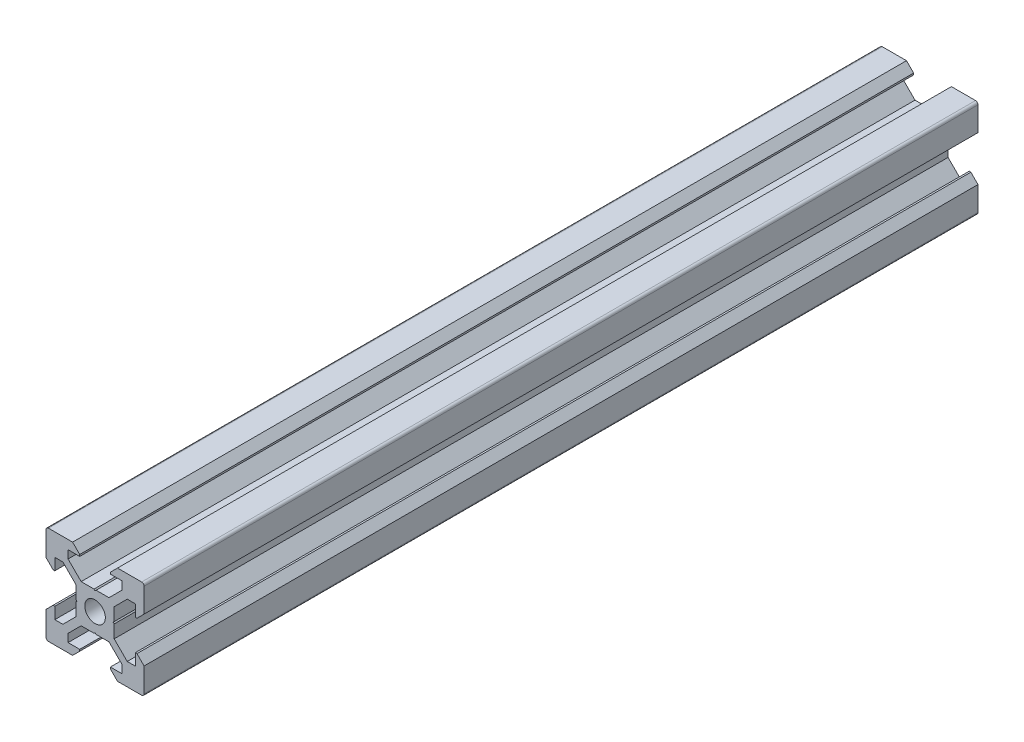
from build123d import *

# Parameters (mm, degrees)
SKETCH1_R           = 2.1
BOSS_EXTRUDE1_DEPTH = 170


with BuildPart() as part:
    # Sketch1 → Boss-Extrude1 (new body)
    with BuildSketch(Plane.XY):
        with BuildLine():
            Line((4.58, -10), (9.5, -10))
            ThreePointArc((9.5, -10), (9.853553391, -9.853553391), (10, -9.5))
            Line((10, -9.5), (10, -4.58))
            Line((10, -4.58), (8.545, -3.125))
            Line((8.545, -3.125), (8.2, -3.125))
            Line((8.2, -3.125), (8.2, -5.5))
            Line((8.2, -5.5), (6.560660172, -5.5))
            Line((6.560660172, -5.5), (3.9, -2.839339828))
            Line((3.9, -2.839339828), (3.9, -0.21))
            Line((3.9, -0.21), (3.69, 0))
            Line((3.69, 0), (3.9, 0.21))
            Line((3.9, 0.21), (3.9, 2.839339828))
            Line((3.9, 2.839339828), (6.560660172, 5.5))
            Line((6.560660172, 5.5), (8.2, 5.5))
            Line((8.2, 5.5), (8.2, 3.125))
            Line((8.2, 3.125), (8.545, 3.125))
            Line((8.545, 3.125), (10, 4.58))
            Line((10, 4.58), (10, 9.5))
            ThreePointArc((10, 9.5), (9.853553391, 9.853553391), (9.5, 10))
            Line((9.5, 10), (4.58, 10))
            Line((4.58, 10), (3.125, 8.545))
            Line((3.125, 8.545), (3.125, 8.2))
            Line((3.125, 8.2), (5.5, 8.2))
            Line((5.5, 8.2), (5.5, 6.560660172))
            Line((5.5, 6.560660172), (2.839339828, 3.9))
            Line((2.839339828, 3.9), (0.21, 3.9))
            Line((0.21, 3.9), (0, 3.69))
            Line((0, 3.69), (-0.21, 3.9))
            Line((-0.21, 3.9), (-2.839339828, 3.9))
            Line((-2.839339828, 3.9), (-5.5, 6.560660172))
            Line((-5.5, 6.560660172), (-5.5, 8.2))
            Line((-5.5, 8.2), (-3.125, 8.2))
            Line((-3.125, 8.2), (-3.125, 8.545))
            Line((-3.125, 8.545), (-4.58, 10))
            Line((-4.58, 10), (-9.5, 10))
            ThreePointArc((-9.5, 10), (-9.853553391, 9.853553391), (-10, 9.5))
            Line((-10, 9.5), (-10, 4.58))
            Line((-10, 4.58), (-8.545, 3.125))
            Line((-8.545, 3.125), (-8.2, 3.125))
            Line((-8.2, 3.125), (-8.2, 5.5))
            Line((-8.2, 5.5), (-6.560660172, 5.5))
            Line((-6.560660172, 5.5), (-3.9, 2.839339828))
            Line((-3.9, 2.839339828), (-3.9, 0.21))
            Line((-3.9, 0.21), (-3.69, 0))
            Line((-3.69, 0), (-3.9, -0.21))
            Line((-3.9, -0.21), (-3.9, -2.839339828))
            Line((-3.9, -2.839339828), (-6.560660172, -5.5))
            Line((-6.560660172, -5.5), (-8.2, -5.5))
            Line((-8.2, -5.5), (-8.2, -3.125))
            Line((-8.2, -3.125), (-8.545, -3.125))
            Line((-8.545, -3.125), (-10, -4.58))
            Line((-10, -4.58), (-10, -9.5))
            ThreePointArc((-10, -9.5), (-9.853553391, -9.853553391), (-9.5, -10))
            Line((-9.5, -10), (-4.58, -10))
            Line((-4.58, -10), (-3.125, -8.545))
            Line((-3.125, -8.545), (-3.125, -8.2))
            Line((-3.125, -8.2), (-5.5, -8.2))
            Line((-5.5, -8.2), (-5.5, -6.560660172))
            Line((-5.5, -6.560660172), (-2.839339828, -3.9))
            Line((-2.839339828, -3.9), (-0.21, -3.9))
            Line((-0.21, -3.9), (0, -3.69))
            Line((0, -3.69), (0.21, -3.9))
            Line((0.21, -3.9), (2.839339828, -3.9))
            Line((2.839339828, -3.9), (5.5, -6.560660172))
            Line((5.5, -6.560660172), (5.5, -8.2))
            Line((5.5, -8.2), (3.125, -8.2))
            Line((3.125, -8.2), (3.125, -8.545))
            Line((3.125, -8.545), (4.58, -10))
        make_face()
        Circle(SKETCH1_R, mode=Mode.SUBTRACT)
    extrude(amount=BOSS_EXTRUDE1_DEPTH)


solid = part.part
